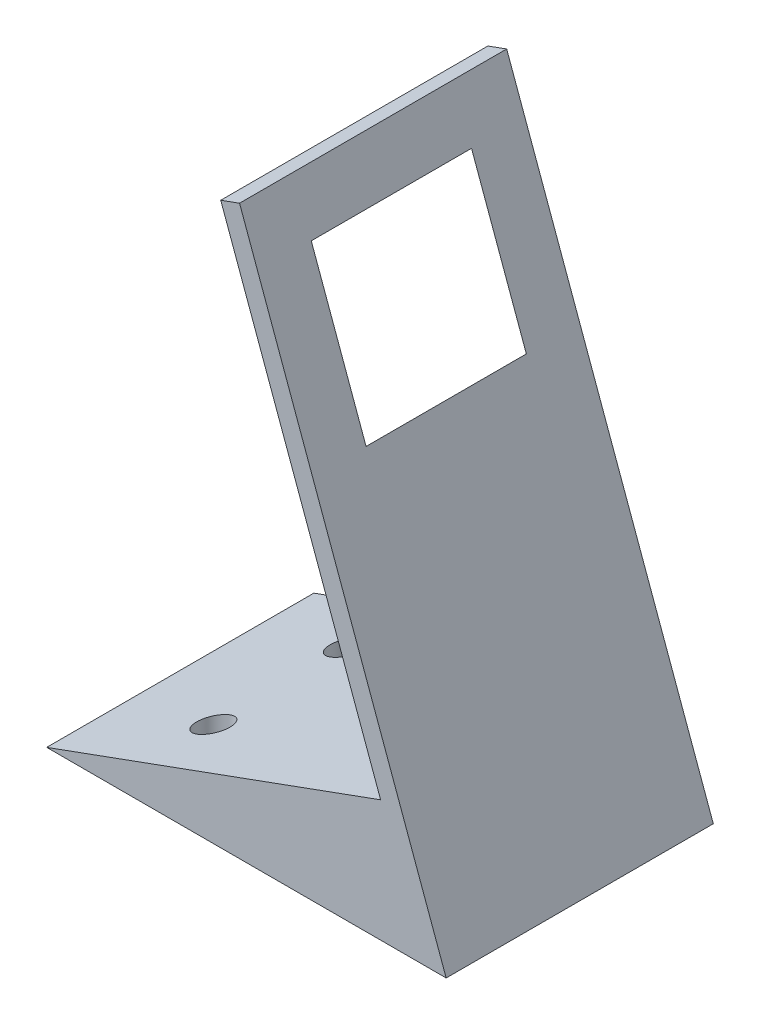
from build123d import *

# Parameters (mm, degrees)
BOSS_EXTRUDE1_DEPTH = 40
CUT_EXTRUDE1_REACH  = 113.371
SKETCH2_R           = 1.5
CUT_EXTRUDE3_REACH  = 115.371
CUT_EXTRUDE3_START  = -2
SKETCH2_4_R         = 2.5
SKETCH2_4_R_2       = 1.5


with BuildPart() as part:
    # Sketch1 → Boss-Extrude1 (new body)
    with BuildSketch(Plane.XY):
        Polygon((50, 18.198511713), (0, 0), (59.816249889, 0), (28.87766783, 85.003055598), (26.058589967, 83.976995168), align=None)
    extrude(amount=BOSS_EXTRUDE1_DEPTH)

    # Sketch2 → Cut-Extrude1 (cut, up to next)
    with BuildSketch(Plane.XZ, mode=Mode.PRIVATE) as cut_extrude1_sk1:
        with Locations((14.954062472, 30)):
            Circle(SKETCH2_R)
    cut_extrude1_tool1 = extrude(cut_extrude1_sk1.sketch, amount=-CUT_EXTRUDE1_REACH, mode=Mode.PRIVATE) & part.part
    # Sketch2 → Cut-Extrude1 (cut, up to next)
    with BuildSketch(Plane.XZ, mode=Mode.PRIVATE) as cut_extrude1_sk2:
        with Locations((44.862187417, 30)):
            Circle(SKETCH2_R)
    cut_extrude1_tool2 = extrude(cut_extrude1_sk2.sketch, amount=-CUT_EXTRUDE1_REACH, mode=Mode.PRIVATE) & part.part
    cut_extrude1_1 = cut_extrude1_tool1.solids().sort_by_distance((14.954062, 0, 30))[0]
    add(cut_extrude1_1, mode=Mode.SUBTRACT)
    cut_extrude1_2 = cut_extrude1_tool2.solids().sort_by_distance((44.862187, 0, 30))[0]
    add(cut_extrude1_2, mode=Mode.SUBTRACT)
    cut_extrude1 = cut_extrude1_1 + cut_extrude1_2  # Cut-Extrude1 as one shape, for the pattern or mirror that repeats it

    # Sketch2_4 → Cut-Extrude3 (cut, up to next)
    with BuildSketch(Plane.XZ.offset(CUT_EXTRUDE3_START), mode=Mode.PRIVATE) as cut_extrude3_sk1:
        with Locations((14.954062472, 30)):
            Circle(SKETCH2_4_R)
        with Locations((14.954062472, 30)):
            Circle(SKETCH2_4_R_2, mode=Mode.SUBTRACT)
    cut_extrude3_tool1 = extrude(cut_extrude3_sk1.sketch, amount=-CUT_EXTRUDE3_REACH, mode=Mode.PRIVATE) & part.part
    # Sketch2_4 → Cut-Extrude3 (cut, up to next)
    with BuildSketch(Plane.XZ.offset(CUT_EXTRUDE3_START), mode=Mode.PRIVATE) as cut_extrude3_sk2:
        with Locations((44.862187417, 30)):
            Circle(SKETCH2_4_R)
    cut_extrude3_tool2 = extrude(cut_extrude3_sk2.sketch, amount=-CUT_EXTRUDE3_REACH, mode=Mode.PRIVATE) & part.part
    cut_extrude3_1 = cut_extrude3_tool1.solids().sort_by_distance((12.524773, 2, 30))[0]
    add(cut_extrude3_1, mode=Mode.SUBTRACT)
    cut_extrude3_2 = cut_extrude3_tool2.solids().sort_by_distance((44.862187, 2, 30))[0]
    add(cut_extrude3_2, mode=Mode.SUBTRACT)
    cut_extrude3 = cut_extrude3_1 + cut_extrude3_2  # Cut-Extrude3 as one shape, for the pattern or mirror that repeats it

    # Mirror1: Cut-Extrude1, Cut-Extrude3 across plane
    add(cut_extrude1.mirror(Plane.XY.offset(20)), mode=Mode.SUBTRACT)
    add(cut_extrude3.mirror(Plane.XY.offset(20)), mode=Mode.SUBTRACT)

    # Sketch3 → Cut-Loft1 section 0
    with BuildSketch(Plane(origin=(50, 18.198511713, 0), x_dir=(0, 0, 1), z_dir=(-0.9396926207859103, -0.3420201433256634, 0))):
        with BuildLine():
            Line((5, 65), (35, 65))
            Line((35, 65), (35, 35))
            Line((35, 35), (5, 35))
            Line((5, 35), (5, 65))
        make_face()
    # Sketch4 → Cut-Loft1 section 1
    with BuildSketch(Plane(origin=(52.819077862, 19.224572143, 0), x_dir=(0, 0, -1), z_dir=(0.9396926207859103, 0.3420201433256634, 0))):
        with BuildLine():
            Line((-8, 62), (-32, 62))
            Line((-32, 62), (-32, 38))
            Line((-32, 38), (-8, 38))
            Line((-8, 38), (-8, 62))
        make_face()
    loft(mode=Mode.SUBTRACT)


solid = part.part
